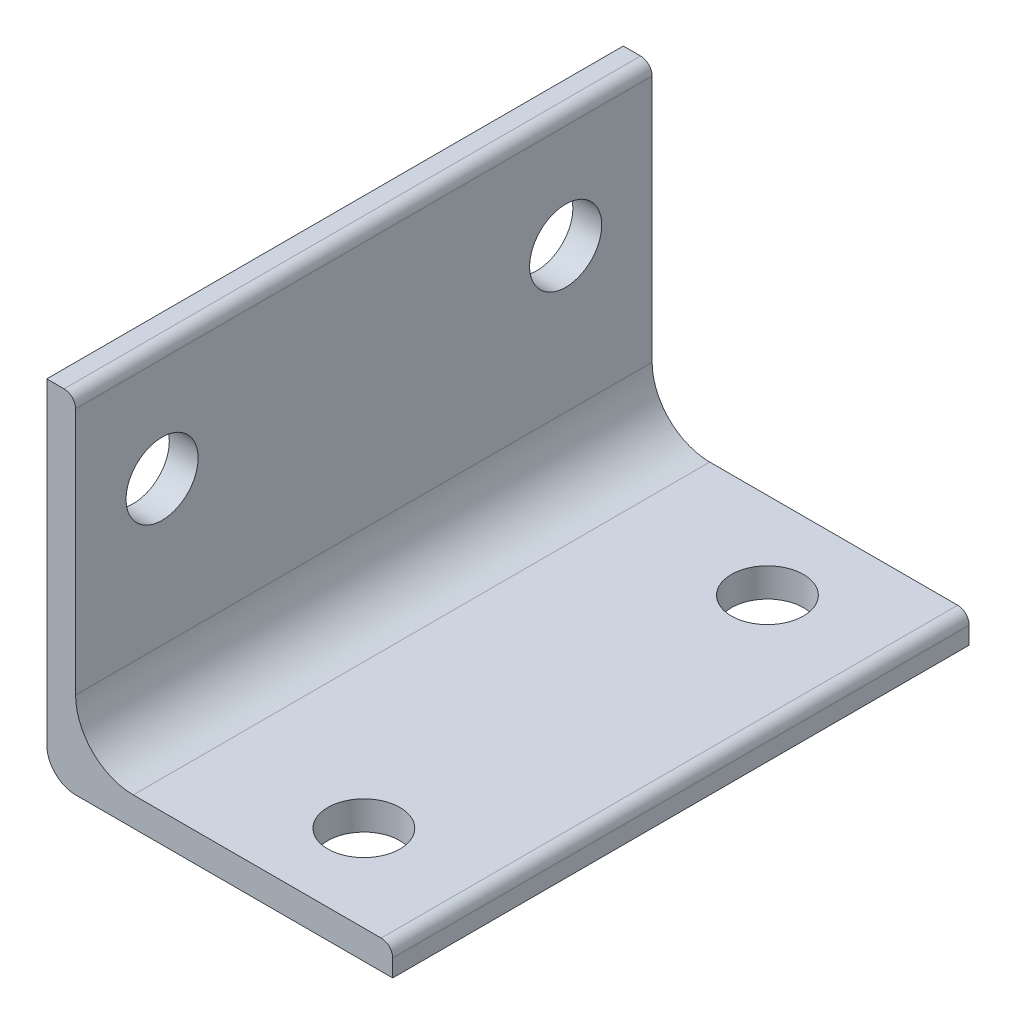
from build123d import *

# Parameters (mm, degrees)
BOSS_EXTRUDE1_DEPTH                      = 63.5
F_5_16_0_3125_DIAMETER_HOLE1_D           = 7.9375
F_5_16_0_3125_DIAMETER_HOLE1_ON_FACE_2_D = 7.9375


with BuildPart() as part:
    # Sketch3 → Boss-Extrude1 (new body)
    with BuildSketch(Plane.XY):
        with BuildLine():
            Line((0, 6.35), (0, 33.655))
            ThreePointArc((0, 33.655), (-0.371974388, 34.553025612), (-1.27, 34.925))
            Line((-1.27, 34.925), (-3.175, 34.925))
            Line((-3.175, 34.925), (-3.175, 0))
            ThreePointArc((-3.175, 0), (-2.24506403, -2.24506403), (0, -3.175))
            Line((0, -3.175), (34.925, -3.175))
            Line((34.925, -3.175), (34.925, -1.27))
            ThreePointArc((34.925, -1.27), (34.553025612, -0.371974388), (33.655, 0))
            Line((33.655, 0), (6.35, 0))
            ThreePointArc((6.35, 0), (1.859871939, 1.859871939), (0, 6.35))
        make_face()
    extrude(amount=BOSS_EXTRUDE1_DEPTH)

    # 5/16 (0.3125) Diameter Hole1 (through all)
    with Locations(Plane(origin=(22.225, 0, 53.975), x_dir=(1, 0, 0), z_dir=(0, 1, 0))):
        with Locations((0, 0), (0, 44.45)):
            Hole(F_5_16_0_3125_DIAMETER_HOLE1_D / 2)

    # 5/16 (0.3125) Diameter Hole1 on face 2 (through all)
    with Locations(Plane(origin=(0, 22.225, 9.525), x_dir=(0, 0, 1), z_dir=(1, 0, 0))):
        with Locations((0, 0), (44.45, 0)):
            Hole(F_5_16_0_3125_DIAMETER_HOLE1_ON_FACE_2_D / 2)


solid = part.part
